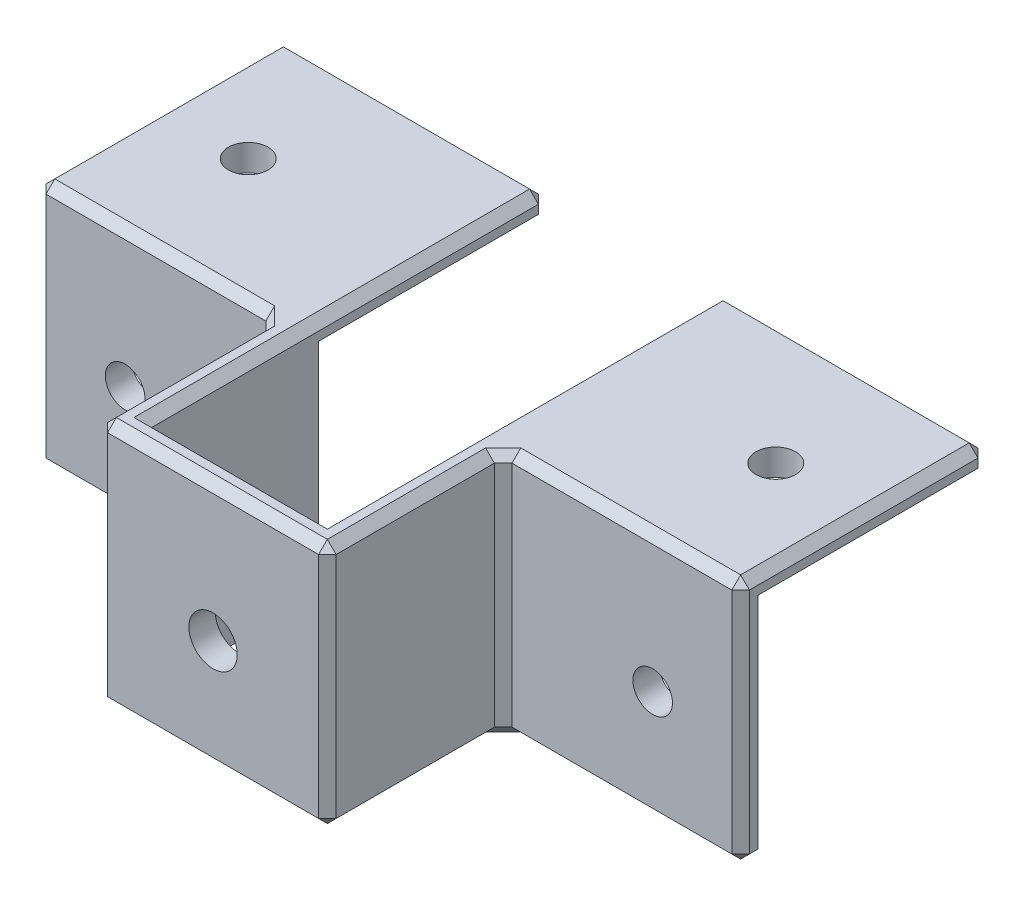
from build123d import *

# Parameters (mm, degrees)
SKETCH2_W                      = 27
SKETCH2_H                      = 25
SKETCH2_W_2                    = 3
BOSS_EXTRUDE1_DEPTH            = 3
SKETCH2_3_W                    = 3
SKETCH2_3_H                    = 25
BOSS_EXTRUDE2_DEPTH            = 20
BOSS_EXTRUDE3_START            = 20
SKETCH2_4_W                    = 20
SKETCH2_4_H                    = 25
BOSS_EXTRUDE3_DEPTH            = 3
BOSS_EXTRUDE4_START            = 12.5
SKETCH3_W                      = 27
SKETCH3_H                      = 28
BOSS_EXTRUDE4_DEPTH            = 3
CBORE_FOR_M4_SHCS1_D           = 4.5
CBORE_FOR_M4_SHCS1_DEPTH       = 10
CBORE_FOR_M4_SHCS1_CBORE_D     = 4.502
CBORE_FOR_M4_SHCS1_CBORE_DEPTH = 4
CBORE_FOR_M4_SHCS1_TIP         = 1.351936393
CBORE_FOR_M4_SHCS2_D           = 4.5
CBORE_FOR_M4_SHCS2_DEPTH       = 10
CBORE_FOR_M4_SHCS2_CBORE_D     = 4.503
CBORE_FOR_M4_SHCS2_CBORE_DEPTH = 4
CBORE_FOR_M4_SHCS2_TIP         = 1.351936393
CHAMFER1_SIZE                  = 1


with BuildPart() as part:
    # Sketch2 → Boss-Extrude1 (new body)
    with BuildSketch(Plane.XY):
        with Locations((-26.5, 0)):
            Rectangle(SKETCH2_W, SKETCH2_H)
        with Locations((26.5, 0)):
            Rectangle(SKETCH2_W, SKETCH2_H)
        with Locations((-11.5, 0)):
            Rectangle(SKETCH2_W_2, SKETCH2_H)
        with Locations((11.5, 0)):
            Rectangle(SKETCH2_W_2, SKETCH2_H)
    extrude(amount=-BOSS_EXTRUDE1_DEPTH)

    # Sketch2_3 → Boss-Extrude2 (add)
    with BuildSketch(Plane.XY):
        with Locations((-11.5, 0)):
            Rectangle(SKETCH2_3_W, SKETCH2_3_H)
        with Locations((11.5, 0)):
            Rectangle(SKETCH2_3_W, SKETCH2_3_H)
    extrude(amount=BOSS_EXTRUDE2_DEPTH)

    # Sketch2_4 → Boss-Extrude3 (add)
    with BuildSketch(Plane.XY.offset(BOSS_EXTRUDE3_START)):
        Rectangle(SKETCH2_4_W, SKETCH2_4_H)
    extrude(amount=-BOSS_EXTRUDE3_DEPTH)

    # Sketch3 → Boss-Extrude4 (add)
    with BuildSketch(Plane(origin=(0, 0, 0), x_dir=(1, 0, 0), z_dir=(0, 1, 0)).offset(BOSS_EXTRUDE4_START)):
        with Locations((-26.5, 14)):
            Rectangle(SKETCH3_W, SKETCH3_H)
        Polygon((-13, 28), (-13, 0), (-10, 0), (-10, 3), (-10, 28), align=None)
        Polygon((-10, 0), (-13, 0), (-13, -20), (13, -20), (13, 0), (10, 0), (10, -17), (-10, -17), align=None)
        with Locations((26.5, 14)):
            Rectangle(SKETCH3_W, SKETCH3_H)
        Polygon((10, 0), (13, 0), (13, 28), (10, 28), (10, 3), align=None)
    extrude(amount=BOSS_EXTRUDE4_DEPTH)

    # Sketch6 → CBORE for M5 Hex Head Cap Screw1 (revolve, cut)
    with BuildSketch(Plane(origin=(0, 0, 20), x_dir=(0, -1, 0), z_dir=(1, 0, 0))):
        Polygon((0, 0), (0, 4.652366702), (2.75, 3), (2.75, 3.65), (2.7505, 0), align=None)
    revolve(axis=Axis((0, 0, 26.35), (0, 0, -1)), mode=Mode.SUBTRACT)

    # CBORE for M4 SHCS1
    with Locations(Plane.XY):
        with Locations((30, 0), (-30, 0)):
            CounterBoreHole(CBORE_FOR_M4_SHCS1_D / 2, CBORE_FOR_M4_SHCS1_CBORE_D / 2, CBORE_FOR_M4_SHCS1_CBORE_DEPTH, depth=CBORE_FOR_M4_SHCS1_DEPTH)
            with Locations((0, 0, -(CBORE_FOR_M4_SHCS1_DEPTH + CBORE_FOR_M4_SHCS1_TIP / 2))):  # 118° drill point
                Cone(0, CBORE_FOR_M4_SHCS1_D / 2, CBORE_FOR_M4_SHCS1_TIP, mode=Mode.SUBTRACT)

    # CBORE for M4 SHCS2
    with Locations(Plane(origin=(0, 15.5, 0), x_dir=(1, 0, 0), z_dir=(0, 1, 0))):
        with Locations((30, 14), (-30, 14)):
            CounterBoreHole(CBORE_FOR_M4_SHCS2_D / 2, CBORE_FOR_M4_SHCS2_CBORE_D / 2, CBORE_FOR_M4_SHCS2_CBORE_DEPTH, depth=CBORE_FOR_M4_SHCS2_DEPTH)
            with Locations((0, 0, -(CBORE_FOR_M4_SHCS2_DEPTH + CBORE_FOR_M4_SHCS2_TIP / 2))):  # 118° drill point
                Cone(0, CBORE_FOR_M4_SHCS2_D / 2, CBORE_FOR_M4_SHCS2_TIP, mode=Mode.SUBTRACT)

    # Chamfer1
    chamfer1_edges = [part.edges().sort_by_distance(p)[0] for p in [
        (-10, 0, -3),
        (-26.5, -12.5, 0),
        (-13, 1.5, 0),
        (0, -12.5, 20),
        (-13, -12.5, 10),
        (-13, 1.5, 20),
        (-40, 0, -3),
        (0, -12.5, 17),
        (13, 1.5, 0),
        (40, 1.5, 0),
        (26.5, -12.5, 0),
        (40, -12.5, -1.5),
        (10, -12.5, 7),
        (10, 0, -3),
        (40, 0, -3),
        (25, -12.5, -3),
        (13, 1.5, 20),
        (13, -12.5, 10),
        (-25, -12.5, -3),
        (-13, 15.5, 10),
        (40, 12.5, -15.5),
        (25, 12.5, -28),
        (-40, 1.5, 0),
        (40, 14, -28),
        (10, 12.5, -15.5),
        (10, 14, -28),
        (-10, 15.5, -5.5),
        (-25, 15.5, -28),
        (-10, 14, -28),
        (-40, 15.5, -14),
        (-40, 14, -28),
        (-26.5, 15.5, 0),
        (0, 15.5, 20),
        (13, 15.5, 10),
        (26.5, 15.5, 0),
        (40, 15.5, -14),
        (25, 15.5, -28),
        (10, 15.5, -5.5),
        (0, 15.5, 17),
        (-40, 12.5, -15.5),
        (-25, 12.5, -28),
        (-10, 12.5, -15.5),
        (-40, -12.5, -1.5),
        (-10, -12.5, 7),
    ]]
    chamfer(chamfer1_edges, length=CHAMFER1_SIZE)


solid = part.part
